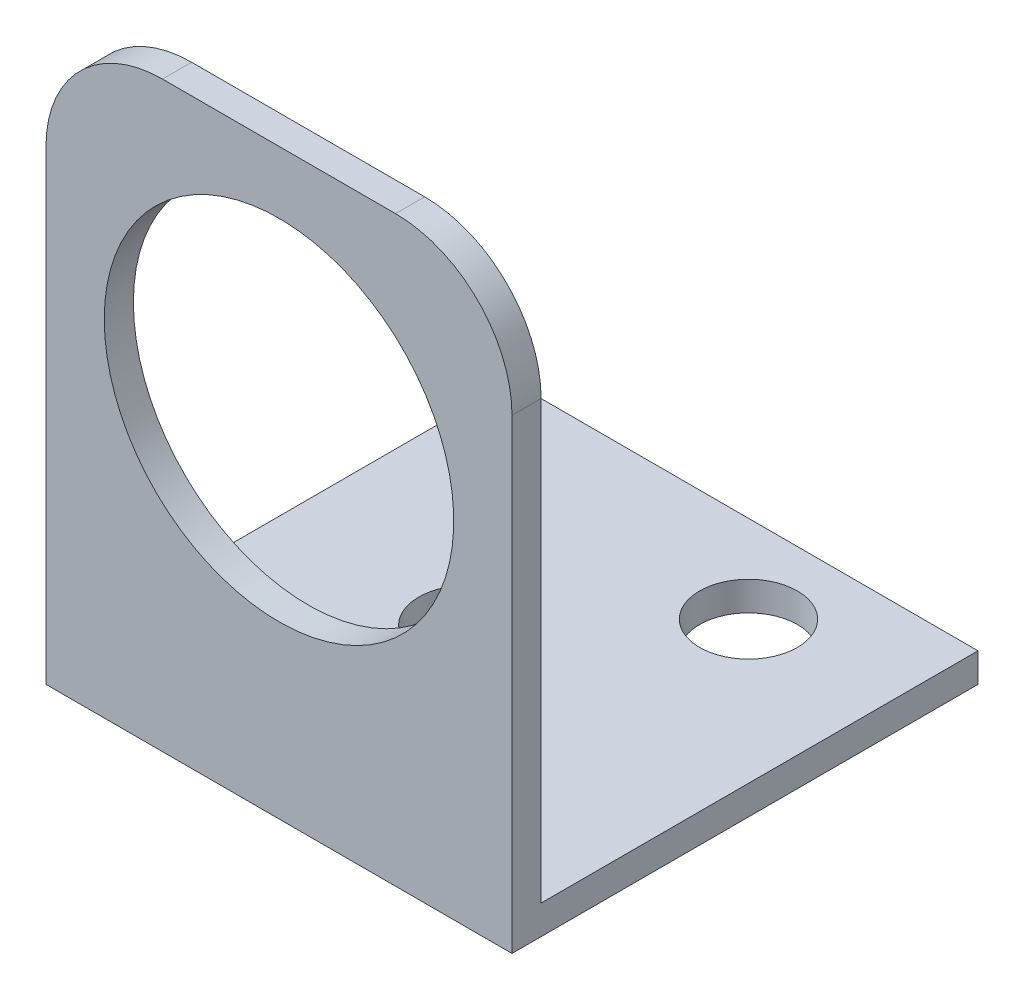
from build123d import *

# Parameters (mm, degrees)
BOSS_EXTRUDE1_DEPTH = 25.4
CUT_EXTRUDE1_REACH  = 3.587
SKETCH2_R           = 9.525
FILLET1_R           = 6.35
CUT_EXTRUDE2_REACH  = 33.75
SKETCH3_R           = 2.667


with BuildPart() as part:
    # Sketch1 → Boss-Extrude1 (new body)
    with BuildSketch(Plane(origin=(0, 0, 0), x_dir=(0, 0, -1), z_dir=(1, 0, 0))):
        Polygon((1.5875, 1.5875), (25.4, 1.5875), (25.4, 0), (0, 0), (0, 31.75), (1.5875, 31.75), align=None)
    extrude(amount=BOSS_EXTRUDE1_DEPTH)

    # Sketch2 → Cut-Extrude1 (cut, up to next)
    with BuildSketch(Plane(origin=(0, 0, -1.5875), x_dir=(-1, 0, 0), z_dir=(0, 0, -1)), mode=Mode.PRIVATE) as cut_extrude1_sk1:
        with Locations((-12.7, 18.830747356)):
            Circle(SKETCH2_R)
    cut_extrude1_tool1 = extrude(cut_extrude1_sk1.sketch, amount=-CUT_EXTRUDE1_REACH, mode=Mode.PRIVATE) & part.part
    add(cut_extrude1_tool1.solids().sort_by_distance((12.7, 18.830747, -1.5875))[0], mode=Mode.SUBTRACT)

    # Fillet1
    fillet1_edges = [part.edges().sort_by_distance(p)[0] for p in [
        (25.4, 31.75, -0.79375),
        (0, 31.75, -0.79375),
    ]]
    fillet(fillet1_edges, radius=FILLET1_R)

    # Sketch3 → Cut-Extrude2 (cut, up to next)
    with BuildSketch(Plane.XZ, mode=Mode.PRIVATE) as cut_extrude2_sk1:
        with Locations((17.653, -20.6375)):
            Circle(SKETCH3_R)
    cut_extrude2_tool1 = extrude(cut_extrude2_sk1.sketch, amount=-CUT_EXTRUDE2_REACH, mode=Mode.PRIVATE) & part.part
    add(cut_extrude2_tool1.solids().sort_by_distance((17.653, 0, -20.6375))[0], mode=Mode.SUBTRACT)
    # Sketch3 → Cut-Extrude2 (cut, up to next)
    with BuildSketch(Plane.XZ, mode=Mode.PRIVATE) as cut_extrude2_sk2:
        with Locations((10.287, -12.7)):
            Circle(SKETCH3_R)
    cut_extrude2_tool2 = extrude(cut_extrude2_sk2.sketch, amount=-CUT_EXTRUDE2_REACH, mode=Mode.PRIVATE) & part.part
    add(cut_extrude2_tool2.solids().sort_by_distance((10.287, 0, -12.7))[0], mode=Mode.SUBTRACT)


solid = part.part
